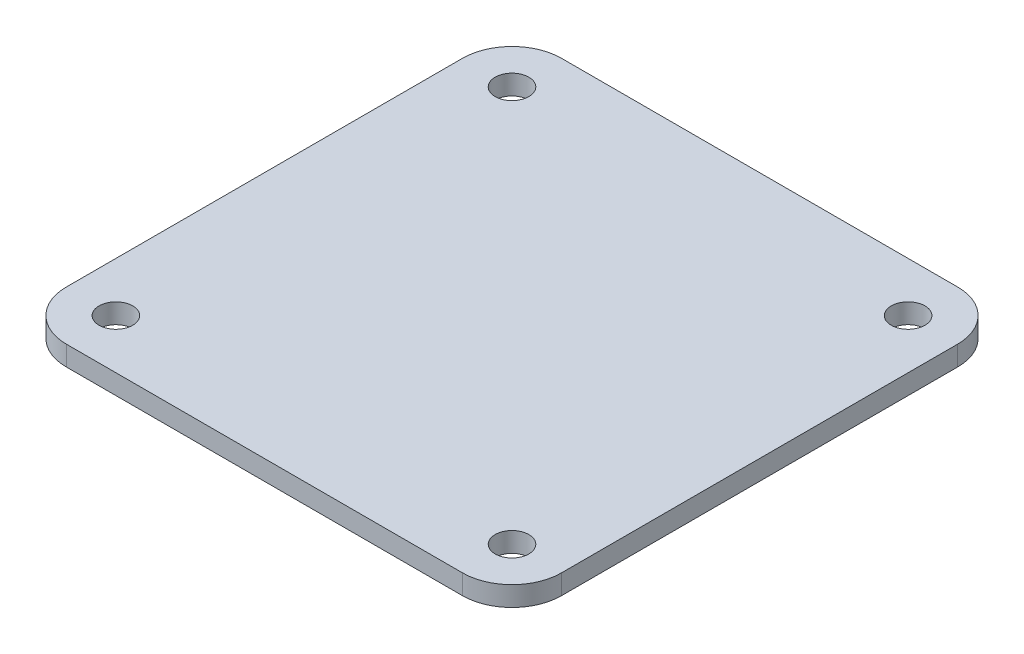
from build123d import *

# Parameters (mm, degrees)
SKETCH1_R           = 1.7
BOSS_EXTRUDE1_DEPTH = 2


with BuildPart() as part:
    # Sketch1 → Boss-Extrude1 (new body)
    with BuildSketch(Plane(origin=(0, -2, 0), x_dir=(-1, 0, 0), z_dir=(0, -1, 0))):
        with BuildLine():
            Line((25, -20), (25, 20))
            ThreePointArc((25, 20), (23.535533906, 23.535533906), (20, 25))
            Line((20, 25), (-20, 25))
            ThreePointArc((-20, 25), (-23.535533906, 23.535533906), (-25, 20))
            Line((-25, 20), (-25, -20))
            ThreePointArc((-25, -20), (-23.535533906, -23.535533906), (-20, -25))
            Line((-20, -25), (20, -25))
            ThreePointArc((20, -25), (23.535533906, -23.535533906), (25, -20))
        make_face()
        with Locations((20, -20)):
            Circle(SKETCH1_R, mode=Mode.SUBTRACT)
        with Locations((-20, -20)):
            Circle(SKETCH1_R, mode=Mode.SUBTRACT)
        with Locations((20, 20)):
            Circle(SKETCH1_R, mode=Mode.SUBTRACT)
        with Locations((-20, 20)):
            Circle(SKETCH1_R, mode=Mode.SUBTRACT)
    extrude(amount=BOSS_EXTRUDE1_DEPTH)


solid = part.part
